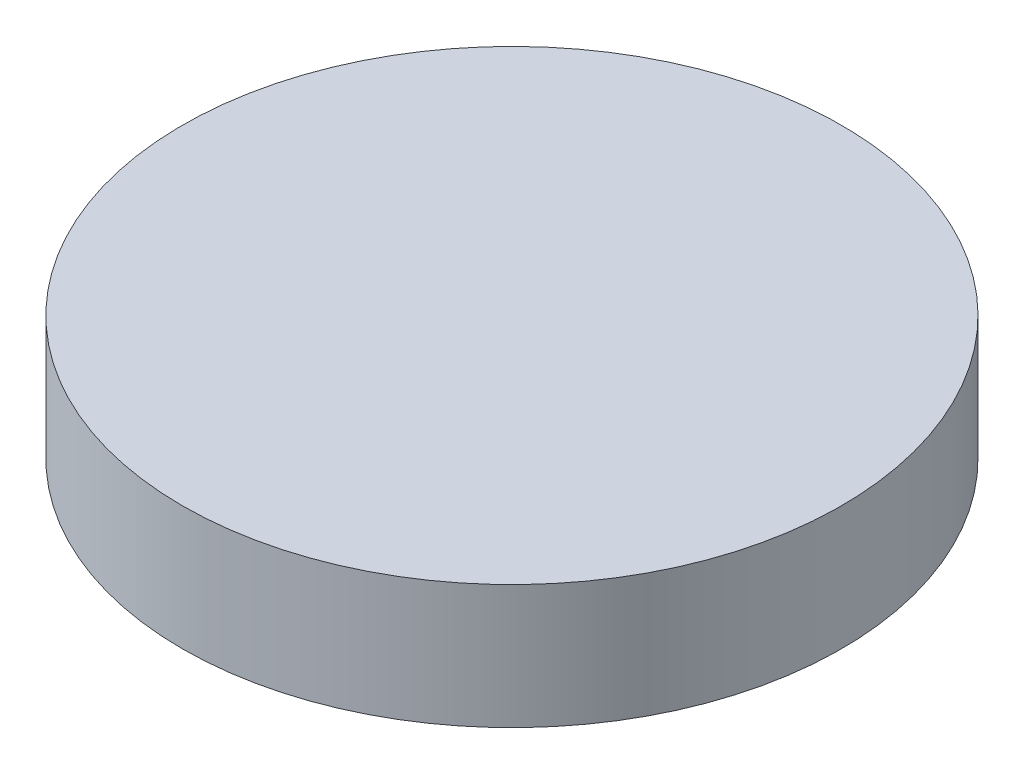
from build123d import *

# Parameters (mm, degrees)
SKETCH_1_R      = 50.8
EXTRUDE_1_DEPTH = 19.1


with BuildPart() as part:
    # 草图1 → 凸台-拉伸1 (new body)
    with BuildSketch(Plane(origin=(0, 0, 0), x_dir=(1, 0, 0), z_dir=(0, 1, 0))):
        with Locations(Location((0, 0, 0), (0, 0, 270))):  # turned: the seam where the file's is
            Circle(SKETCH_1_R)
    extrude(amount=EXTRUDE_1_DEPTH)


solid = part.part
